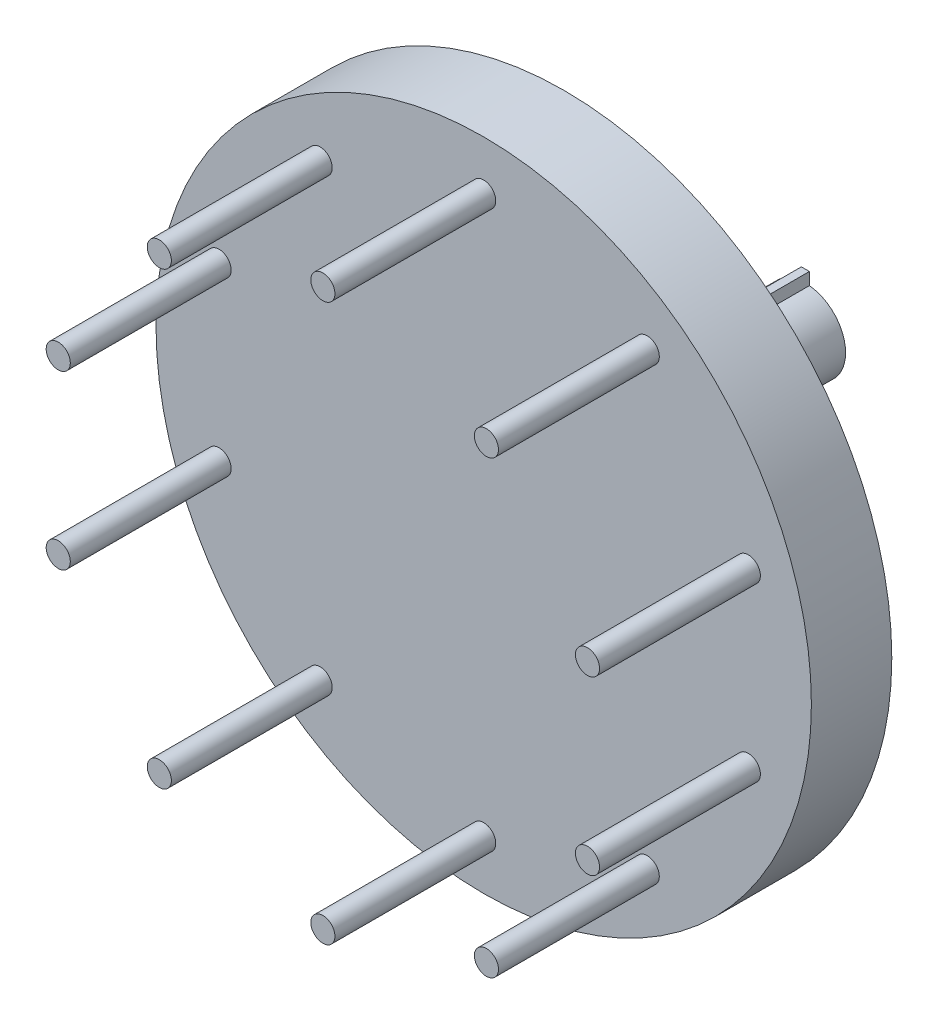
from build123d import *

# Parameters (mm, degrees)
SKETCH1_R              = 1.5
BOSS_EXTRUDE1_DEPTH    = 20
BOSS_EXTRUDE1_2_DEPTH  = 20
BOSS_EXTRUDE1_3_DEPTH  = 20
BOSS_EXTRUDE1_4_DEPTH  = 20
BOSS_EXTRUDE1_5_DEPTH  = 20
BOSS_EXTRUDE1_6_DEPTH  = 20
BOSS_EXTRUDE1_7_DEPTH  = 20
BOSS_EXTRUDE1_8_DEPTH  = 20
BOSS_EXTRUDE1_9_DEPTH  = 20
BOSS_EXTRUDE1_10_DEPTH = 20
SKETCH2_R              = 40.75
BOSS_EXTRUDE2_DEPTH    = 10
SKETCH3_R              = 5
BOSS_EXTRUDE3_DEPTH    = 30
SKETCH4_W              = 1
SKETCH4_H              = 2
BOSS_EXTRUDE4_DEPTH    = 30


with BuildPart() as part:
    # Sketch1 → Boss-Extrude1 (new body)
    with BuildSketch(Plane.XY):
        with Locations((0, 34.6)):
            Circle(SKETCH1_R)
    extrude(amount=BOSS_EXTRUDE1_DEPTH)



with BuildPart() as body_2:
    # Sketch1 → Boss-Extrude1 2 (new body)
    with BuildSketch(Plane.XY):
        with Locations((20.337369729, 27.991988005)):
            Circle(SKETCH1_R)
    extrude(amount=BOSS_EXTRUDE1_2_DEPTH)


with BuildPart() as body_3:
    # Sketch1 → Boss-Extrude1 3 (new body)
    with BuildSketch(Plane.XY):
        with Locations((32.906555464, 10.691988005)):
            Circle(SKETCH1_R)
    extrude(amount=BOSS_EXTRUDE1_3_DEPTH)


with BuildPart() as body_4:
    # Sketch1 → Boss-Extrude1 4 (new body)
    with BuildSketch(Plane.XY):
        with Locations((32.906555464, -10.691988005)):
            Circle(SKETCH1_R)
    extrude(amount=BOSS_EXTRUDE1_4_DEPTH)


with BuildPart() as body_5:
    # Sketch1 → Boss-Extrude1 5 (new body)
    with BuildSketch(Plane.XY):
        with Locations((20.337369729, -27.991988005)):
            Circle(SKETCH1_R)
    extrude(amount=BOSS_EXTRUDE1_5_DEPTH)


with BuildPart() as body_6:
    # Sketch1 → Boss-Extrude1 6 (new body)
    with BuildSketch(Plane.XY):
        with Locations((0, -34.6)):
            Circle(SKETCH1_R)
    extrude(amount=BOSS_EXTRUDE1_6_DEPTH)


with BuildPart() as body_7:
    # Sketch1 → Boss-Extrude1 7 (new body)
    with BuildSketch(Plane.XY):
        with Locations((-20.337369729, -27.991988005)):
            Circle(SKETCH1_R)
    extrude(amount=BOSS_EXTRUDE1_7_DEPTH)


with BuildPart() as body_8:
    # Sketch1 → Boss-Extrude1 8 (new body)
    with BuildSketch(Plane.XY):
        with Locations((-32.906555464, -10.691988005)):
            Circle(SKETCH1_R)
    extrude(amount=BOSS_EXTRUDE1_8_DEPTH)


with BuildPart() as body_9:
    # Sketch1 → Boss-Extrude1 9 (new body)
    with BuildSketch(Plane.XY):
        with Locations((-32.906555464, 10.691988005)):
            Circle(SKETCH1_R)
    extrude(amount=BOSS_EXTRUDE1_9_DEPTH)


with BuildPart() as body_10:
    # Sketch1 → Boss-Extrude1 10 (new body)
    with BuildSketch(Plane.XY):
        with Locations((-20.337369729, 27.991988005)):
            Circle(SKETCH1_R)
    extrude(amount=BOSS_EXTRUDE1_10_DEPTH)


with BuildPart() as part_1:
    add(part.part)

    add(body_2.part)  # Boss-Extrude2 merges body 2

    add(body_3.part)  # Boss-Extrude2 merges body 3

    add(body_4.part)  # Boss-Extrude2 merges body 4

    add(body_5.part)  # Boss-Extrude2 merges body 5

    add(body_6.part)  # Boss-Extrude2 merges body 6

    add(body_7.part)  # Boss-Extrude2 merges body 7

    add(body_8.part)  # Boss-Extrude2 merges body 8

    add(body_9.part)  # Boss-Extrude2 merges body 9

    add(body_10.part)  # Boss-Extrude2 merges body 10
    # Sketch2 → Boss-Extrude2 (add)
    with BuildSketch(Plane(origin=(0, 0, 0), x_dir=(-1, 0, 0), z_dir=(0, 0, -1))):
        Circle(SKETCH2_R)
    extrude(amount=BOSS_EXTRUDE2_DEPTH)

    # Sketch3 → Boss-Extrude3 (add)
    with BuildSketch(Plane(origin=(0, 0, -10), x_dir=(-1, 0, 0), z_dir=(0, 0, -1))):
        Circle(SKETCH3_R)
    extrude(amount=BOSS_EXTRUDE3_DEPTH)

    # Sketch4 → Boss-Extrude4 (add)
    with BuildSketch(Plane(origin=(0, 0, -40), x_dir=(-1, 0, 0), z_dir=(0, 0, -1))):
        with Locations((0, 5.5)):
            Rectangle(SKETCH4_W, SKETCH4_H)
        with Locations((0, -5.5)):
            Rectangle(SKETCH4_W, SKETCH4_H)
    extrude(amount=-BOSS_EXTRUDE4_DEPTH)


solid = part_1.part
